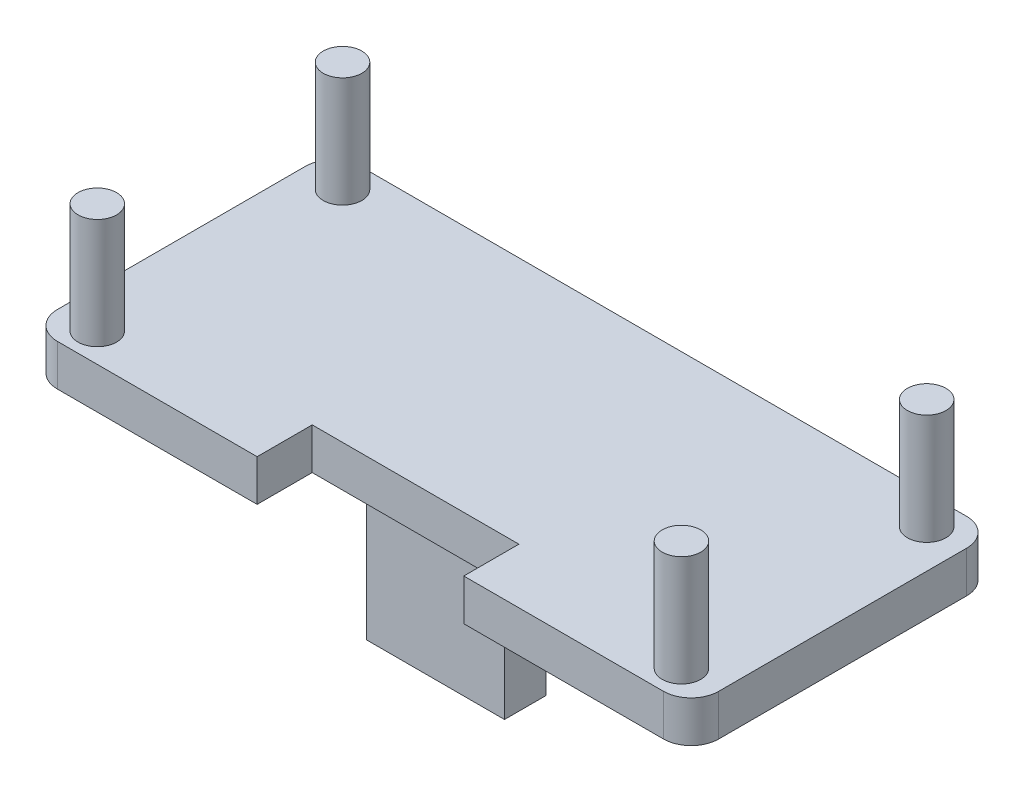
from build123d import *

# Parameters (mm, degrees)
SKETCH1_W           = 48
SKETCH1_H           = 22
BOSS_EXTRUDE1_DEPTH = 3
SKETCH2_R           = 1.4
BOSS_EXTRUDE2_DEPTH = 8
SKETCH3_W           = 10
SKETCH3_H           = 3
BOSS_EXTRUDE3_DEPTH = 10
SKETCH4_W           = 15
SKETCH4_H           = 4
CUT_EXTRUDE1_DEPTH  = 10
FILLET1_R           = 2


with BuildPart() as part:
    # Sketch1 → Boss-Extrude1 (new body)
    with BuildSketch(Plane(origin=(0, 0, 0), x_dir=(1, 0, 0), z_dir=(0, 1, 0))):
        Rectangle(SKETCH1_W, SKETCH1_H)
    extrude(amount=BOSS_EXTRUDE1_DEPTH)

    # Sketch2 → Boss-Extrude2 (add)
    with BuildSketch(Plane(origin=(0, 3, 0), x_dir=(1, 0, 0), z_dir=(0, 1, 0))):
        with Locations((-21.2, 8.899999974)):
            Circle(SKETCH2_R)
        with Locations((-21.2, -8.899999974)):
            Circle(SKETCH2_R)
        with Locations((21.2, 8.899999974)):
            Circle(SKETCH2_R)
        with Locations((21.2, -8.899999974)):
            Circle(SKETCH2_R)
    extrude(amount=BOSS_EXTRUDE2_DEPTH)

    # Sketch3 → Boss-Extrude3 (add)
    with BuildSketch(Plane.XZ):
        with Locations((0, 4.044761195)):
            Rectangle(SKETCH3_W, SKETCH3_H)
    extrude(amount=BOSS_EXTRUDE3_DEPTH)

    # Sketch4 → Cut-Extrude1 (cut)
    with BuildSketch(Plane.XZ):
        with Locations((0, 9)):
            Rectangle(SKETCH4_W, SKETCH4_H)
    extrude(amount=-CUT_EXTRUDE1_DEPTH, mode=Mode.SUBTRACT)

    # Fillet1
    fillet1_edges = [part.edges().sort_by_distance(p)[0] for p in [
        (24, 1.5, 11),
        (-24, 1.5, 11),
        (-24, 1.5, -11),
        (24, 1.5, -11),
    ]]
    fillet(fillet1_edges, radius=FILLET1_R)


solid = part.part
